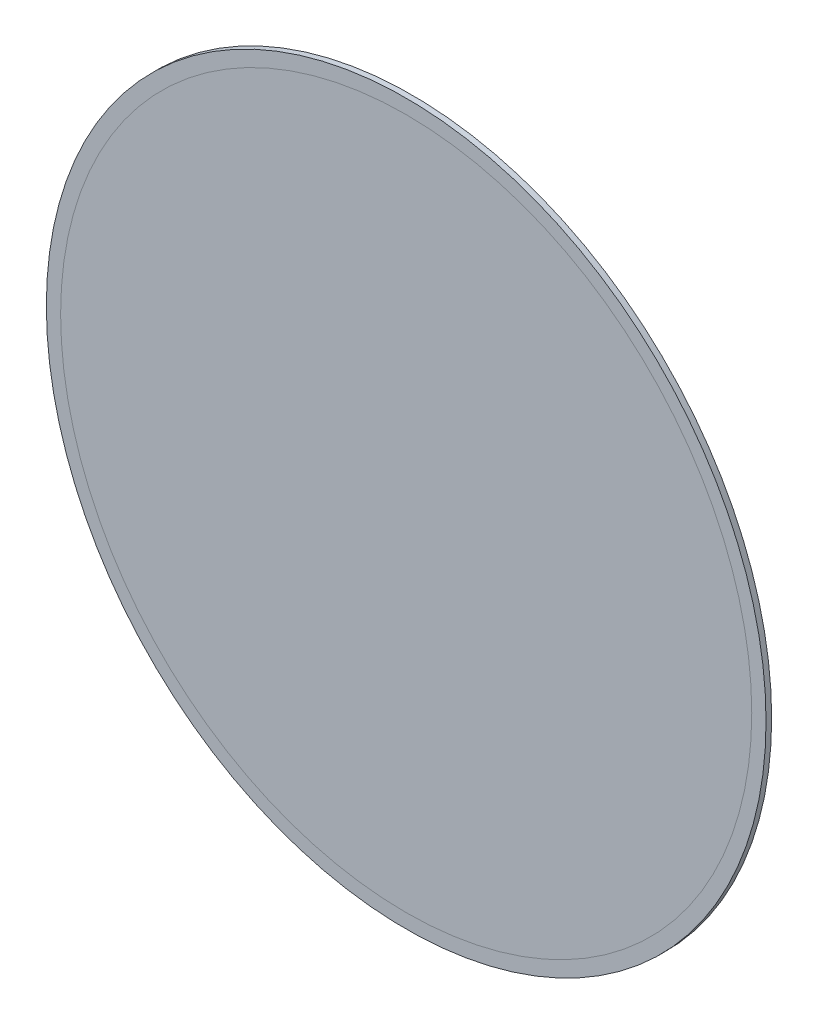
from build123d import *

# Parameters (mm, degrees)
SKETCH1_R                          = 320
QUARTZ_WINDOW_THICKNESS_5_MM_DEPTH = 5


with BuildPart() as part:
    # Sketch1 → Quartz Window Thickness _ 5 mm (new body)
    with BuildSketch(Plane.XY):
        Circle(SKETCH1_R)
    extrude(amount=QUARTZ_WINDOW_THICKNESS_5_MM_DEPTH)


solid = part.part
